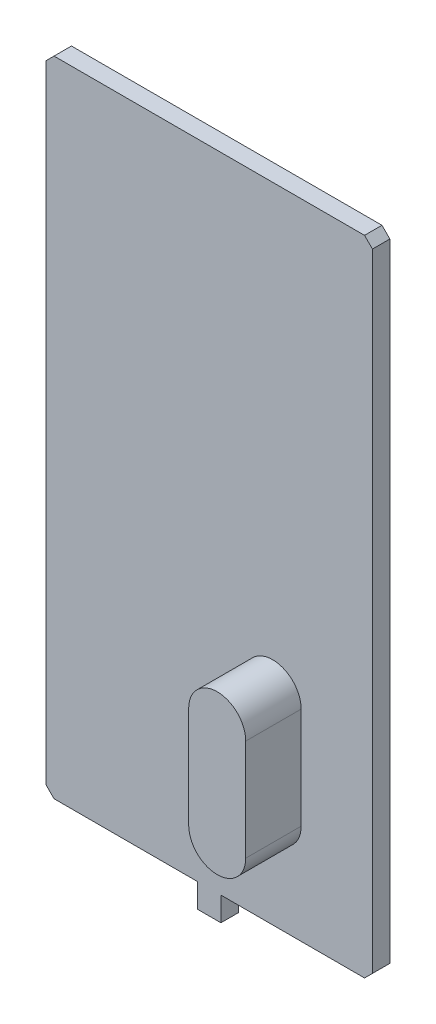
from build123d import *

# Parameters (mm, degrees)
SKETCH_1_W      = 20.6
SKETCH_1_H      = 40.6
EXTRUDE_1_DEPTH = 1.1
EXTRUDE_2_DEPTH = 3.5
SKETCH_3_W      = 1.46922728
SKETCH_3_H      = 3.03026103
EXTRUDE_3_DEPTH = 1.1
CHAMFER_1_SIZE  = 0.5


with BuildPart() as part:
    # Эскиз1 → Бобышка-Вытянуть1 (new body)
    with BuildSketch(Plane.XY):
        Rectangle(SKETCH_1_W, SKETCH_1_H)
    extrude(amount=EXTRUDE_1_DEPTH)

    # Эскиз2 → Бобышка-Вытянуть2 (add)
    with BuildSketch(Plane.XY.offset(1.1)):
        with BuildLine():
            Line((5.8, -7.6), (5.8, -14))
            ThreePointArc((5.8, -14), (4, -15.8), (2.2, -14))
            Line((2.2, -14), (2.2, -7.6))
            ThreePointArc((2.2, -7.6), (4, -5.8), (5.8, -7.6))
        make_face()
    extrude(amount=EXTRUDE_2_DEPTH)

    # Эскиз3 → Бобышка-Вытянуть3 (add)
    with BuildSketch(Plane.XY.offset(1.1)):
        with Locations((0, -20.3)):
            Rectangle(SKETCH_3_W, SKETCH_3_H)
    extrude(amount=-EXTRUDE_3_DEPTH)

    # Фаска1
    chamfer_1_edges = [part.edges().sort_by_distance(p)[0] for p in [
        (10.3, -20.3, 0.55),
        (-10.3, -20.3, 0.55),
        (-10.3, 20.3, 0.55),
        (10.3, 20.3, 0.55),
    ]]
    chamfer(chamfer_1_edges, length=CHAMFER_1_SIZE)


solid = part.part
